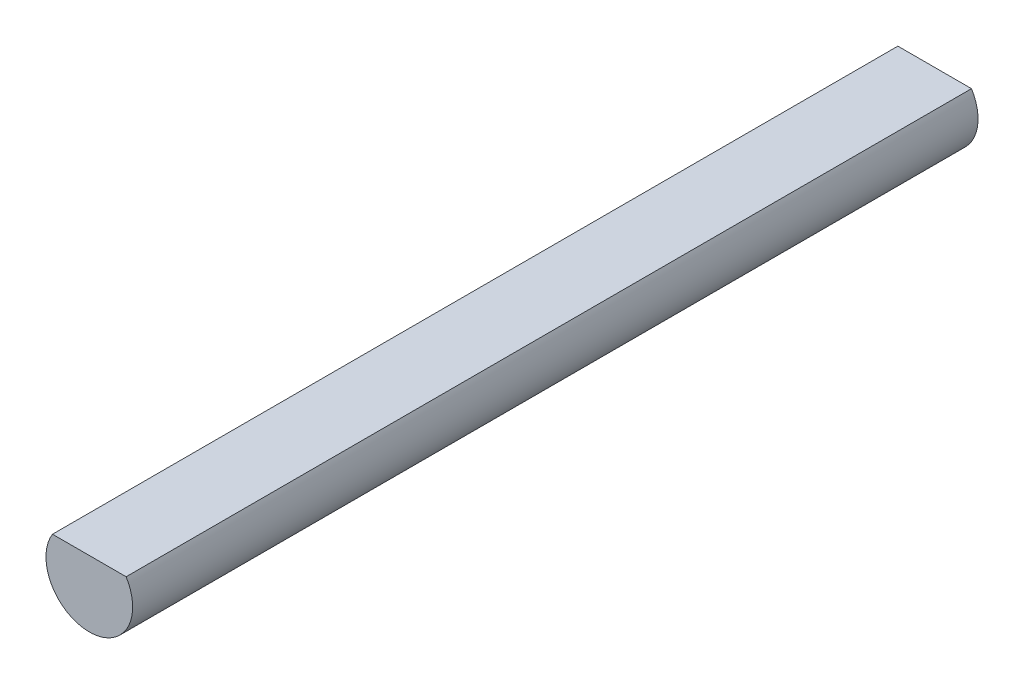
from build123d import *

# Parameters (mm, degrees)
BOSS_EXTRUDE1_DEPTH = 287


with BuildPart() as part:
    # Sketch1 → Boss-Extrude1 (new body, symmetric)
    with BuildSketch(Plane.XY):
        with BuildLine():
            Line((-25, 0), (25, 0))
            ThreePointArc((25, 0), (0, -45), (-25, 0))
        make_face()
    extrude(amount=BOSS_EXTRUDE1_DEPTH, both=True)


solid = part.part
